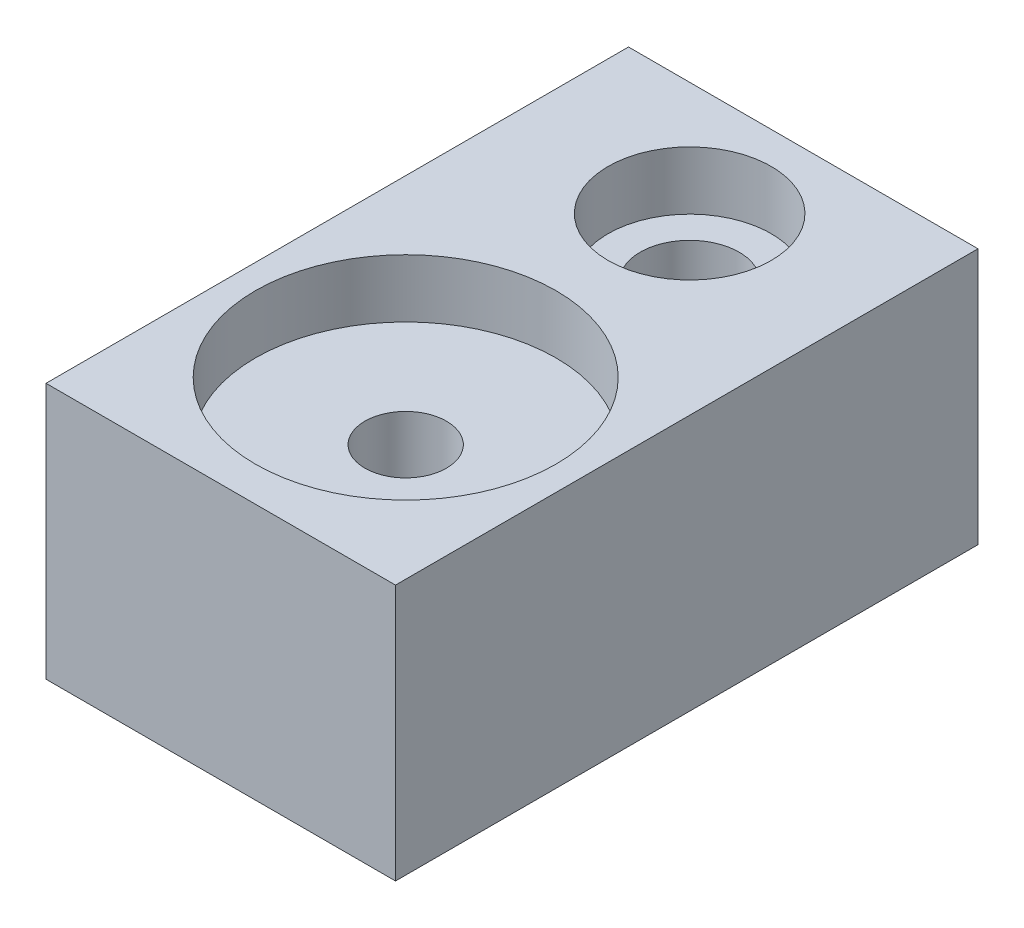
from build123d import *

# Parameters (mm, degrees)
SKETCH_1_W          = 30
SKETCH_1_H          = 50
SKETCH_1_R          = 3.5
SKETCH_1_R_2        = 4.25
EXTRUDE_1_DEPTH     = 22
SKETCH_2_R          = 12.9
CUT_EXTRUDE_1_DEPTH = 5
SKETCH_3_R          = 6
CUT_EXTRUDE_2_DEPTH = 3.5
SKETCH_4_R          = 7
CUT_EXTRUDE_3_DEPTH = 5


with BuildPart() as part:
    # 草图1 → 凸台-拉伸1 (new body)
    with BuildSketch(Plane(origin=(0, 0, 0), x_dir=(1, 0, 0), z_dir=(0, 1, 0))):
        Rectangle(SKETCH_1_W, SKETCH_1_H)
        with Locations((0, -9.125)):
            Circle(SKETCH_1_R, mode=Mode.SUBTRACT)
        with Locations((0, 15.25)):
            Circle(SKETCH_1_R_2, mode=Mode.SUBTRACT)
    extrude(amount=EXTRUDE_1_DEPTH)

    # 草图2 → 切除-拉伸1 (cut)
    with BuildSketch(Plane(origin=(0, 22, 0), x_dir=(1, 0, 0), z_dir=(0, 1, 0))):
        with Locations((0, -9.125)):
            Circle(SKETCH_2_R)
    extrude(amount=-CUT_EXTRUDE_1_DEPTH, mode=Mode.SUBTRACT)

    # 草图3 → 切除-拉伸2 (cut)
    with BuildSketch(Plane.XZ):
        with Locations((0, 9.125)):
            Circle(SKETCH_3_R)
    extrude(amount=-CUT_EXTRUDE_2_DEPTH, mode=Mode.SUBTRACT)

    # 草图4 → 切除-拉伸3 (cut)
    with BuildSketch(Plane(origin=(0, 22, 0), x_dir=(1, 0, 0), z_dir=(0, 1, 0))):
        with Locations((0, 15.25)):
            Circle(SKETCH_4_R)
    extrude(amount=-CUT_EXTRUDE_3_DEPTH, mode=Mode.SUBTRACT)


solid = part.part
